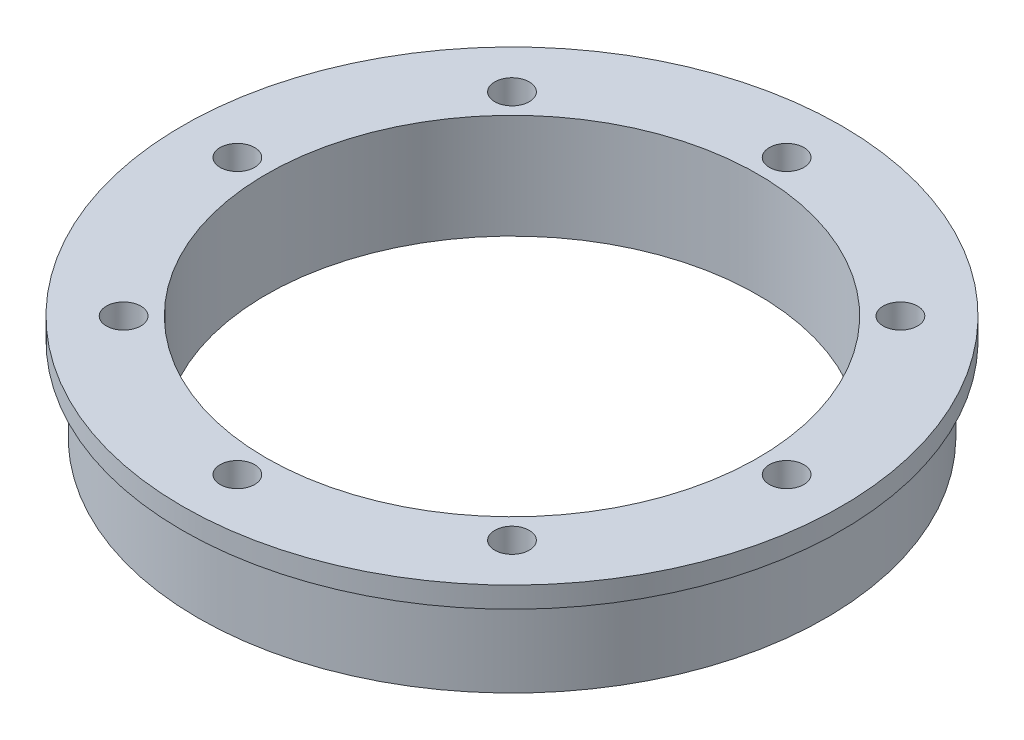
from build123d import *

# Parameters (mm, degrees)
SKETCH_1_R         = 30
SKETCH_1_R_2       = 23.5
EXTRUDE_1_DEPTH    = 10
SKETCH_2_R         = 31.5
SKETCH_2_R_2       = 30
EXTRUDE_2_DEPTH    = 2
HOLE_WIZARD_M4_1_D = 3.3


with BuildPart() as part:
    # 草图1 → 凸台-拉伸1 (new body)
    with BuildSketch(Plane(origin=(0, 0, 0), x_dir=(1, 0, 0), z_dir=(0, 1, 0))):
        Circle(SKETCH_1_R)
        Circle(SKETCH_1_R_2, mode=Mode.SUBTRACT)
    extrude(amount=EXTRUDE_1_DEPTH)

    # 草图2 → 凸台-拉伸2 (add)
    with BuildSketch(Plane(origin=(0, 10, 0), x_dir=(1, 0, 0), z_dir=(0, 1, 0))):
        Circle(SKETCH_2_R)
        Circle(SKETCH_2_R_2, mode=Mode.SUBTRACT)
    extrude(amount=-EXTRUDE_2_DEPTH)

    # M4 螺纹孔1 (through all)
    with Locations(Plane(origin=(-18.561553006, 0, 18.561553006), x_dir=(0, 0, -1), z_dir=(0, -1, 0))):
        with Locations((0, 0), (-7.688446994, 18.561553006), (18.561553006, -7.688446994), (37.123106012, 0), (44.811553006, 18.561553006), (37.123106012, 37.123106012), (18.561553006, 44.811553006), (0, 37.123106012)):
            Hole(HOLE_WIZARD_M4_1_D / 2)


solid = part.part
